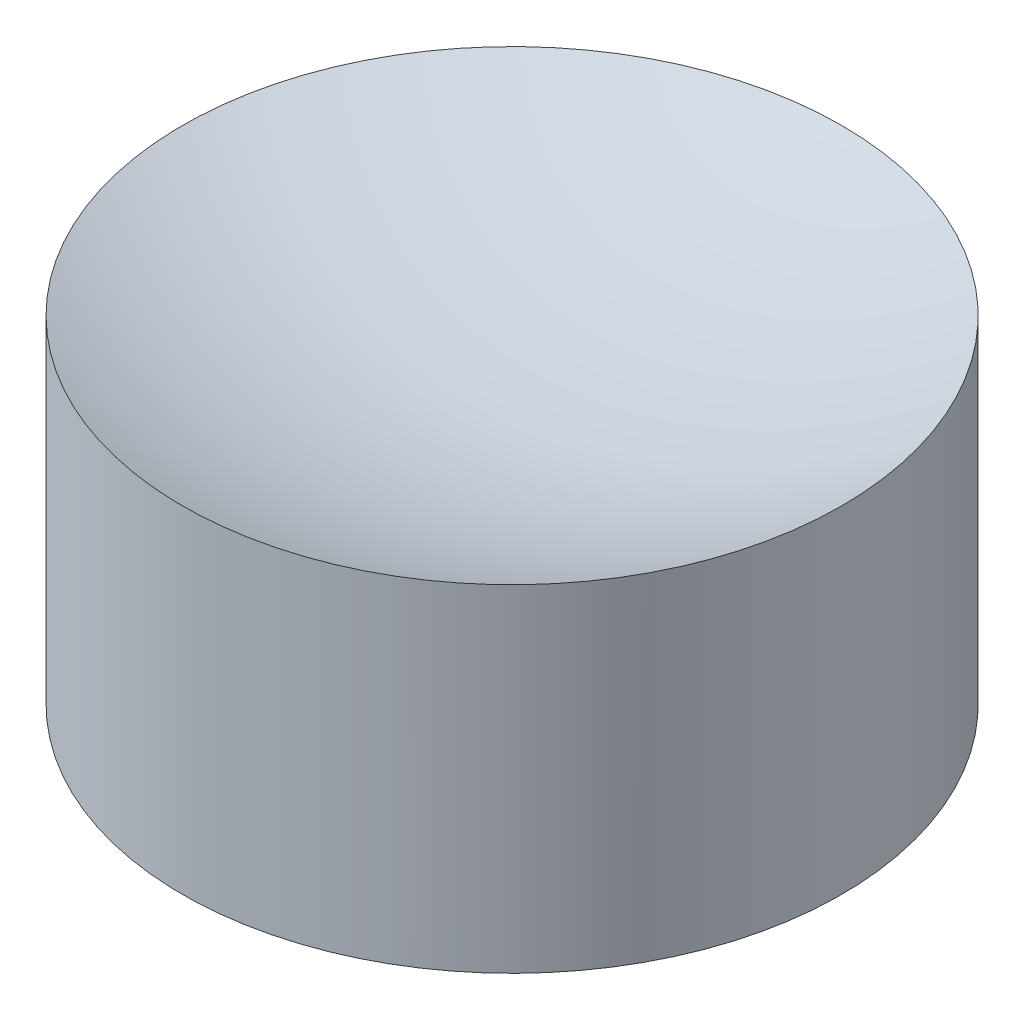
from build123d import *


with BuildPart() as part:
    # Sketch1 → Revolve1 (revolve)
    with BuildSketch(Plane.XY):
        with BuildLine():
            Line((1.5, 0), (8, 0))
            Line((8, 0), (8, 8.16969722))
            ThreePointArc((8, 8.16969722), (4.086192874, 6.921873741), (0, 6.5))
            Line((0, 6.5), (0, 5))
            Line((0, 5), (1.5, 5))
            Line((1.5, 5), (1.5, 0))
        make_face()
    revolve(axis=Axis((0, 0, 0), (0, 1, 0)))


solid = part.part
